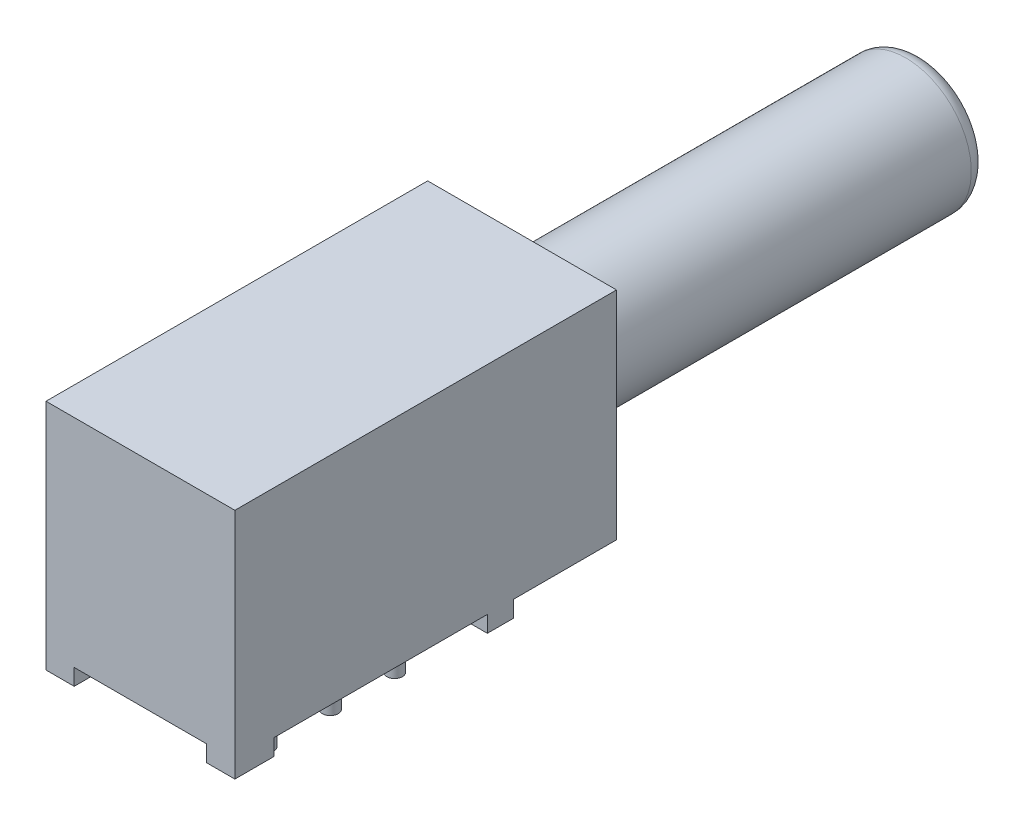
from build123d import *

# Parameters (mm, degrees)
SKETCH1_R           = 0.3048
PINS_DEPTH          = 2.54
PINS_2_DEPTH        = 2.54
PINS_3_DEPTH        = 2.54
PINS_4_DEPTH        = 2.54
PINS_5_DEPTH        = 2.54
PINS_6_DEPTH        = 2.54
SKETCH2_W           = 7.3152
SKETCH2_H           = 10.795
MAIN_BODY_DEPTH     = 8.382
SKETCH3_W           = 1.0922
SKETCH3_H           = 1.524
SKETCH3_H_2         = 1.016
FEET_DEPTH          = 0.635
SKETCH5_W           = 7.3152
SKETCH5_H           = 8.382
BOSS_EXTRUDE5_DEPTH = 3.9878
SKETCH4_R           = 2.54
CUP_DEPTH           = 19.4818
SKETCH6_R           = 2.3495
SPRING_DEPTH        = 6.5532
FILLET1_R           = 0.635


with BuildPart() as part:
    # Sketch1 → Pins (new body)
    with BuildSketch(Plane(origin=(0, 0, 0), x_dir=(1, 0, 0), z_dir=(0, 1, 0))):
        with Locations(Location((0, 0, 0), (0, 0, 270))):
            Circle(SKETCH1_R)
    extrude(amount=-PINS_DEPTH)



with BuildPart() as body_2:
    # Sketch1 → Pins 2 (new body)
    with BuildSketch(Plane(origin=(0, 0, 0), x_dir=(1, 0, 0), z_dir=(0, 1, 0))):
        with Locations(Location((0, -2.4892, 0), (0, 0, 270))):
            Circle(SKETCH1_R)
    extrude(amount=-PINS_2_DEPTH)


with BuildPart() as body_3:
    # Sketch1 → Pins 3 (new body)
    with BuildSketch(Plane(origin=(0, 0, 0), x_dir=(1, 0, 0), z_dir=(0, 1, 0))):
        with Locations(Location((0, -4.9784, 0), (0, 0, 270))):
            Circle(SKETCH1_R)
    extrude(amount=-PINS_3_DEPTH)


with BuildPart() as body_4:
    # Sketch1 → Pins 4 (new body)
    with BuildSketch(Plane(origin=(0, 0, 0), x_dir=(1, 0, 0), z_dir=(0, 1, 0))):
        with Locations(Location((2.5146, 0, 0), (0, 0, 270))):
            Circle(SKETCH1_R)
    extrude(amount=-PINS_4_DEPTH)


with BuildPart() as body_5:
    # Sketch1 → Pins 5 (new body)
    with BuildSketch(Plane(origin=(0, 0, 0), x_dir=(1, 0, 0), z_dir=(0, 1, 0))):
        with Locations(Location((2.5146, -2.4892, 0), (0, 0, 270))):
            Circle(SKETCH1_R)
    extrude(amount=-PINS_5_DEPTH)


with BuildPart() as body_6:
    # Sketch1 → Pins 6 (new body)
    with BuildSketch(Plane(origin=(0, 0, 0), x_dir=(1, 0, 0), z_dir=(0, 1, 0))):
        with Locations(Location((2.5146, -4.9784, 0), (0, 0, 270))):
            Circle(SKETCH1_R)
    extrude(amount=-PINS_6_DEPTH)


with BuildPart() as part_1:
    add(part.part)

    add(body_2.part)  # Main Body merges body 2

    add(body_3.part)  # Main Body merges body 3

    add(body_4.part)  # Main Body merges body 4

    add(body_5.part)  # Main Body merges body 5

    add(body_6.part)  # Main Body merges body 6
    # Sketch2 → Main Body (add)
    with BuildSketch(Plane(origin=(0, 0, 0), x_dir=(1, 0, 0), z_dir=(0, 1, 0))):
        with Locations((1.2573, -3.1877)):
            Rectangle(SKETCH2_W, SKETCH2_H)
    extrude(amount=MAIN_BODY_DEPTH)

    # Sketch3 → Feet (add)
    with BuildSketch(Plane.XZ):
        with Locations((-1.8542, 7.8232)):
            Rectangle(SKETCH3_W, SKETCH3_H)
        with Locations((4.3688, 7.8232)):
            Rectangle(SKETCH3_W, SKETCH3_H)
        with Locations((4.3688, -1.7018)):
            Rectangle(SKETCH3_W, SKETCH3_H_2)
        with Locations((-1.8542, -1.7018)):
            Rectangle(SKETCH3_W, SKETCH3_H_2)
    extrude(amount=FEET_DEPTH)

    # Sketch5 → Boss-Extrude5 (add)
    with BuildSketch(Plane(origin=(0, 0, -2.2098), x_dir=(-1, 0, 0), z_dir=(0, 0, -1))):
        with Locations((-1.2573, 4.191)):
            Rectangle(SKETCH5_W, SKETCH5_H)
    extrude(amount=BOSS_EXTRUDE5_DEPTH)

    # Sketch4 → Cup (add)
    with BuildSketch(Plane(origin=(0, 0, -2.2098), x_dir=(-1, 0, 0), z_dir=(0, 0, -1))):
        with Locations((-1.2573, 4.3688)):
            Circle(SKETCH4_R)
    extrude(amount=CUP_DEPTH)

    # Sketch6 → Spring (add)
    with BuildSketch(Plane(origin=(0, 0, -6.1976), x_dir=(-1, 0, 0), z_dir=(0, 0, -1))):
        with Locations((-1.2573, 4.3688)):
            Circle(SKETCH6_R)
    extrude(amount=SPRING_DEPTH)

    # Fillet1
    fillet1_edges = [part_1.edges().sort_by_distance(p)[0] for p in [
        (3.7973, 4.3688, -21.6916),
    ]]
    fillet(fillet1_edges, radius=FILLET1_R)


solid = part_1.part
